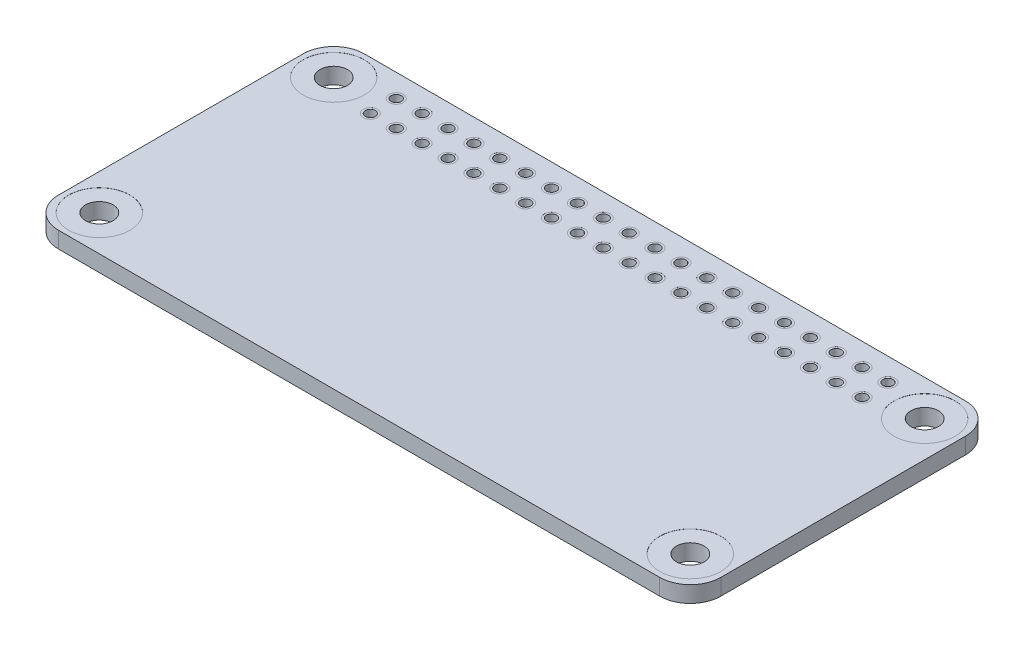
from build123d import *

# Parameters (mm, degrees)
BASES_W                          = 65
BASES_H                          = 30
BASE_DEPTH                       = 0.8
M2_5_CLEARANCE_HOLE_D            = 2.7
FASTENERAREAS_R                  = 3
FASTENERAREAS_R_2                = 1.35
FASTENERAREA_DEPTH               = 0.01
F_1_0_1_DIAMETER_HOLE_IO_D       = 1
SOLDERCONNECTIONCUTS_R           = 0.7
SOLDERCONNECTIONCUTS_R_2         = 0.5
SOLDERCONNECTIONCUT_DEPTH        = 0.001
LP_DIAHOLE_IO_COUNT              = 20
LP_DIAHOLE_IO_PITCH              = 2.54
LP_DIAHOLE_IO_COUNT_DIR2         = 2
LP_DIAHOLE_IO_PITCH_DIR2         = 2.54
LP_DIAHOLE_IO_COPY_1_SKETCH_R    = 0.7
LP_DIAHOLE_IO_COPY_1_SKETCH_R_2  = 0.5
LP_DIAHOLE_IO_COPY_1_DEPTH       = 0.001
LP_DIAHOLE_IO_COPY_2_SKETCH_R    = 0.7
LP_DIAHOLE_IO_COPY_2_SKETCH_R_2  = 0.5
LP_DIAHOLE_IO_COPY_2_DEPTH       = 0.001
LP_DIAHOLE_IO_COPY_3_SKETCH_R    = 0.7
LP_DIAHOLE_IO_COPY_3_SKETCH_R_2  = 0.5
LP_DIAHOLE_IO_COPY_3_DEPTH       = 0.001
LP_DIAHOLE_IO_COPY_4_SKETCH_R    = 0.7
LP_DIAHOLE_IO_COPY_4_SKETCH_R_2  = 0.5
LP_DIAHOLE_IO_COPY_4_DEPTH       = 0.001
LP_DIAHOLE_IO_COPY_5_SKETCH_R    = 0.7
LP_DIAHOLE_IO_COPY_5_SKETCH_R_2  = 0.5
LP_DIAHOLE_IO_COPY_5_DEPTH       = 0.001
LP_DIAHOLE_IO_COPY_6_SKETCH_R    = 0.7
LP_DIAHOLE_IO_COPY_6_SKETCH_R_2  = 0.5
LP_DIAHOLE_IO_COPY_6_DEPTH       = 0.001
LP_DIAHOLE_IO_COPY_7_SKETCH_R    = 0.7
LP_DIAHOLE_IO_COPY_7_SKETCH_R_2  = 0.5
LP_DIAHOLE_IO_COPY_7_DEPTH       = 0.001
LP_DIAHOLE_IO_COPY_8_SKETCH_R    = 0.7
LP_DIAHOLE_IO_COPY_8_SKETCH_R_2  = 0.5
LP_DIAHOLE_IO_COPY_8_DEPTH       = 0.001
LP_DIAHOLE_IO_COPY_9_SKETCH_R    = 0.7
LP_DIAHOLE_IO_COPY_9_SKETCH_R_2  = 0.5
LP_DIAHOLE_IO_COPY_9_DEPTH       = 0.001
LP_DIAHOLE_IO_COPY_10_SKETCH_R   = 0.7
LP_DIAHOLE_IO_COPY_10_SKETCH_R_2 = 0.5
LP_DIAHOLE_IO_COPY_10_DEPTH      = 0.001
LP_DIAHOLE_IO_COPY_11_SKETCH_R   = 0.7
LP_DIAHOLE_IO_COPY_11_SKETCH_R_2 = 0.5
LP_DIAHOLE_IO_COPY_11_DEPTH      = 0.001
LP_DIAHOLE_IO_COPY_12_SKETCH_R   = 0.7
LP_DIAHOLE_IO_COPY_12_SKETCH_R_2 = 0.5
LP_DIAHOLE_IO_COPY_12_DEPTH      = 0.001
LP_DIAHOLE_IO_COPY_13_SKETCH_R   = 0.7
LP_DIAHOLE_IO_COPY_13_SKETCH_R_2 = 0.5
LP_DIAHOLE_IO_COPY_13_DEPTH      = 0.001
LP_DIAHOLE_IO_COPY_14_SKETCH_R   = 0.7
LP_DIAHOLE_IO_COPY_14_SKETCH_R_2 = 0.5
LP_DIAHOLE_IO_COPY_14_DEPTH      = 0.001
LP_DIAHOLE_IO_COPY_15_SKETCH_R   = 0.7
LP_DIAHOLE_IO_COPY_15_SKETCH_R_2 = 0.5
LP_DIAHOLE_IO_COPY_15_DEPTH      = 0.001
LP_DIAHOLE_IO_COPY_16_SKETCH_R   = 0.7
LP_DIAHOLE_IO_COPY_16_SKETCH_R_2 = 0.5
LP_DIAHOLE_IO_COPY_16_DEPTH      = 0.001
LP_DIAHOLE_IO_COPY_17_SKETCH_R   = 0.7
LP_DIAHOLE_IO_COPY_17_SKETCH_R_2 = 0.5
LP_DIAHOLE_IO_COPY_17_DEPTH      = 0.001
LP_DIAHOLE_IO_COPY_18_SKETCH_R   = 0.7
LP_DIAHOLE_IO_COPY_18_SKETCH_R_2 = 0.5
LP_DIAHOLE_IO_COPY_18_DEPTH      = 0.001
LP_DIAHOLE_IO_COPY_19_SKETCH_R   = 0.7
LP_DIAHOLE_IO_COPY_19_SKETCH_R_2 = 0.5
LP_DIAHOLE_IO_COPY_19_DEPTH      = 0.001
LP_DIAHOLE_IO_COPY_20_SKETCH_R   = 0.7
LP_DIAHOLE_IO_COPY_20_SKETCH_R_2 = 0.5
LP_DIAHOLE_IO_COPY_20_DEPTH      = 0.001
LP_DIAHOLE_IO_COPY_21_SKETCH_R   = 0.7
LP_DIAHOLE_IO_COPY_21_SKETCH_R_2 = 0.5
LP_DIAHOLE_IO_COPY_21_DEPTH      = 0.001
LP_DIAHOLE_IO_COPY_22_SKETCH_R   = 0.7
LP_DIAHOLE_IO_COPY_22_SKETCH_R_2 = 0.5
LP_DIAHOLE_IO_COPY_22_DEPTH      = 0.001
LP_DIAHOLE_IO_COPY_23_SKETCH_R   = 0.7
LP_DIAHOLE_IO_COPY_23_SKETCH_R_2 = 0.5
LP_DIAHOLE_IO_COPY_23_DEPTH      = 0.001
LP_DIAHOLE_IO_COPY_24_SKETCH_R   = 0.7
LP_DIAHOLE_IO_COPY_24_SKETCH_R_2 = 0.5
LP_DIAHOLE_IO_COPY_24_DEPTH      = 0.001
LP_DIAHOLE_IO_COPY_25_SKETCH_R   = 0.7
LP_DIAHOLE_IO_COPY_25_SKETCH_R_2 = 0.5
LP_DIAHOLE_IO_COPY_25_DEPTH      = 0.001
LP_DIAHOLE_IO_COPY_26_SKETCH_R   = 0.7
LP_DIAHOLE_IO_COPY_26_SKETCH_R_2 = 0.5
LP_DIAHOLE_IO_COPY_26_DEPTH      = 0.001
LP_DIAHOLE_IO_COPY_27_SKETCH_R   = 0.7
LP_DIAHOLE_IO_COPY_27_SKETCH_R_2 = 0.5
LP_DIAHOLE_IO_COPY_27_DEPTH      = 0.001
LP_DIAHOLE_IO_COPY_28_SKETCH_R   = 0.7
LP_DIAHOLE_IO_COPY_28_SKETCH_R_2 = 0.5
LP_DIAHOLE_IO_COPY_28_DEPTH      = 0.001
LP_DIAHOLE_IO_COPY_29_SKETCH_R   = 0.7
LP_DIAHOLE_IO_COPY_29_SKETCH_R_2 = 0.5
LP_DIAHOLE_IO_COPY_29_DEPTH      = 0.001
LP_DIAHOLE_IO_COPY_30_SKETCH_R   = 0.7
LP_DIAHOLE_IO_COPY_30_SKETCH_R_2 = 0.5
LP_DIAHOLE_IO_COPY_30_DEPTH      = 0.001
LP_DIAHOLE_IO_COPY_31_SKETCH_R   = 0.7
LP_DIAHOLE_IO_COPY_31_SKETCH_R_2 = 0.5
LP_DIAHOLE_IO_COPY_31_DEPTH      = 0.001
LP_DIAHOLE_IO_COPY_32_SKETCH_R   = 0.7
LP_DIAHOLE_IO_COPY_32_SKETCH_R_2 = 0.5
LP_DIAHOLE_IO_COPY_32_DEPTH      = 0.001
LP_DIAHOLE_IO_COPY_33_SKETCH_R   = 0.7
LP_DIAHOLE_IO_COPY_33_SKETCH_R_2 = 0.5
LP_DIAHOLE_IO_COPY_33_DEPTH      = 0.001
LP_DIAHOLE_IO_COPY_34_SKETCH_R   = 0.7
LP_DIAHOLE_IO_COPY_34_SKETCH_R_2 = 0.5
LP_DIAHOLE_IO_COPY_34_DEPTH      = 0.001
LP_DIAHOLE_IO_COPY_35_SKETCH_R   = 0.7
LP_DIAHOLE_IO_COPY_35_SKETCH_R_2 = 0.5
LP_DIAHOLE_IO_COPY_35_DEPTH      = 0.001
LP_DIAHOLE_IO_COPY_36_SKETCH_R   = 0.7
LP_DIAHOLE_IO_COPY_36_SKETCH_R_2 = 0.5
LP_DIAHOLE_IO_COPY_36_DEPTH      = 0.001
LP_DIAHOLE_IO_COPY_37_SKETCH_R   = 0.7
LP_DIAHOLE_IO_COPY_37_SKETCH_R_2 = 0.5
LP_DIAHOLE_IO_COPY_37_DEPTH      = 0.001
LP_DIAHOLE_IO_COPY_38_SKETCH_R   = 0.7
LP_DIAHOLE_IO_COPY_38_SKETCH_R_2 = 0.5
LP_DIAHOLE_IO_COPY_38_DEPTH      = 0.001
LP_DIAHOLE_IO_COPY_39_SKETCH_R   = 0.7
LP_DIAHOLE_IO_COPY_39_SKETCH_R_2 = 0.5
LP_DIAHOLE_IO_COPY_39_DEPTH      = 0.001
CORNERRADIUS_R                   = 3
FCHM_COPY_1_SKETCH_R             = 3
FCHM_COPY_1_SKETCH_R_2           = 1.35
FCHM_COPY_1_DEPTH                = 0.01


with BuildPart() as part:
    # BaseS → Base (new, symmetric)
    with BuildSketch(Plane(origin=(0, 0, 0), x_dir=(1, 0, 0), z_dir=(0, 1, 0))):
        Rectangle(BASES_W, BASES_H)
    extrude(amount=BASE_DEPTH, both=True)

    # M2.5 Clearance Hole (through all)
    with Locations(Plane(origin=(0, 0.8, 0), x_dir=(1, 0, 0), z_dir=(0, 1, 0))):
        with Locations((-29, 11.5), (-29, -11.5)):
            m2_5_clearance_hole = Hole(M2_5_CLEARANCE_HOLE_D / 2)

    # FastenerAreaS → FastenerArea (cut)
    with BuildSketch(Plane(origin=(0, 0.8, 0), x_dir=(1, 0, 0), z_dir=(0, 1, 0))):
        with Locations(Location((-29, -11.5, 0), (0, 0, 270))):
            Circle(FASTENERAREAS_R)
        with Locations(Location((-29, -11.5, 0), (0, 0, 270))):
            Circle(FASTENERAREAS_R_2, mode=Mode.SUBTRACT)
        with Locations(Location((-29, 11.5, 0), (0, 0, 270))):
            Circle(FASTENERAREAS_R)
        with Locations(Location((-29, 11.5, 0), (0, 0, 270))):
            Circle(FASTENERAREAS_R_2, mode=Mode.SUBTRACT)
    fastenerarea = extrude(amount=-FASTENERAREA_DEPTH, mode=Mode.SUBTRACT)

    # VM FA: FastenerArea across plane
    add(fastenerarea.mirror(Plane.ZX), mode=Mode.SUBTRACT)

    # Ø1.0 (1) Diameter Hole IO (through all)
    with Locations(Plane(origin=(0, 0.8, 0), x_dir=(1, 0, 0), z_dir=(0, 1, 0))):
        with Locations((-24.13, 12.77)):
            f_1_0_1_diameter_hole_io = Hole(F_1_0_1_DIAMETER_HOLE_IO_D / 2)

    # SolderConnectionCutS → SolderConnectionCut (cut)
    with BuildSketch(Plane(origin=(0, 0.8, 0), x_dir=(1, 0, 0), z_dir=(0, 1, 0))):
        with Locations(Location((-24.13, 12.77, 0), (0, 0, 270))):
            Circle(SOLDERCONNECTIONCUTS_R)
        with Locations(Location((-24.13, 12.77, 0), (0, 0, 270))):
            Circle(SOLDERCONNECTIONCUTS_R_2, mode=Mode.SUBTRACT)
    solderconnectioncut = extrude(amount=-SOLDERCONNECTIONCUT_DEPTH, mode=Mode.SUBTRACT)

    # SCCVM: SolderConnectionCut across plane
    add(solderconnectioncut.mirror(Plane.ZX), mode=Mode.SUBTRACT)

    # LP DiaHole IO: Ø1.0 (1) Diameter Hole IO, SolderConnectionCut 20 × 2
    with Locations(*[(i * LP_DIAHOLE_IO_PITCH, 0, j * LP_DIAHOLE_IO_PITCH_DIR2) for i in range(LP_DIAHOLE_IO_COUNT) for j in range(LP_DIAHOLE_IO_COUNT_DIR2) if (i, j) != (0, 0)]):
        add(f_1_0_1_diameter_hole_io, mode=Mode.SUBTRACT)
        add(solderconnectioncut, mode=Mode.SUBTRACT)

    # LP DiaHole IO copy 1 sketch → LP DiaHole IO copy 1 (cut)
    with BuildSketch(Plane(origin=(0, -0.8, 2.54), x_dir=(1, 0, 0), z_dir=(0, -1, 0))):
        with Locations((-24.13, -12.77)):
            Circle(LP_DIAHOLE_IO_COPY_1_SKETCH_R)
        with Locations((-24.13, -12.77)):
            Circle(LP_DIAHOLE_IO_COPY_1_SKETCH_R_2, mode=Mode.SUBTRACT)
    extrude(amount=-LP_DIAHOLE_IO_COPY_1_DEPTH, mode=Mode.SUBTRACT)

    # LP DiaHole IO copy 2 sketch → LP DiaHole IO copy 2 (cut)
    with BuildSketch(Plane(origin=(2.54, -0.8, 0), x_dir=(1, 0, 0), z_dir=(0, -1, 0))):
        with Locations((-24.13, -12.77)):
            Circle(LP_DIAHOLE_IO_COPY_2_SKETCH_R)
        with Locations((-24.13, -12.77)):
            Circle(LP_DIAHOLE_IO_COPY_2_SKETCH_R_2, mode=Mode.SUBTRACT)
    extrude(amount=-LP_DIAHOLE_IO_COPY_2_DEPTH, mode=Mode.SUBTRACT)

    # LP DiaHole IO copy 3 sketch → LP DiaHole IO copy 3 (cut)
    with BuildSketch(Plane(origin=(2.54, -0.8, 2.54), x_dir=(1, 0, 0), z_dir=(0, -1, 0))):
        with Locations((-24.13, -12.77)):
            Circle(LP_DIAHOLE_IO_COPY_3_SKETCH_R)
        with Locations((-24.13, -12.77)):
            Circle(LP_DIAHOLE_IO_COPY_3_SKETCH_R_2, mode=Mode.SUBTRACT)
    extrude(amount=-LP_DIAHOLE_IO_COPY_3_DEPTH, mode=Mode.SUBTRACT)

    # LP DiaHole IO copy 4 sketch → LP DiaHole IO copy 4 (cut)
    with BuildSketch(Plane(origin=(5.08, -0.8, 0), x_dir=(1, 0, 0), z_dir=(0, -1, 0))):
        with Locations((-24.13, -12.77)):
            Circle(LP_DIAHOLE_IO_COPY_4_SKETCH_R)
        with Locations((-24.13, -12.77)):
            Circle(LP_DIAHOLE_IO_COPY_4_SKETCH_R_2, mode=Mode.SUBTRACT)
    extrude(amount=-LP_DIAHOLE_IO_COPY_4_DEPTH, mode=Mode.SUBTRACT)

    # LP DiaHole IO copy 5 sketch → LP DiaHole IO copy 5 (cut)
    with BuildSketch(Plane(origin=(5.08, -0.8, 2.54), x_dir=(1, 0, 0), z_dir=(0, -1, 0))):
        with Locations((-24.13, -12.77)):
            Circle(LP_DIAHOLE_IO_COPY_5_SKETCH_R)
        with Locations((-24.13, -12.77)):
            Circle(LP_DIAHOLE_IO_COPY_5_SKETCH_R_2, mode=Mode.SUBTRACT)
    extrude(amount=-LP_DIAHOLE_IO_COPY_5_DEPTH, mode=Mode.SUBTRACT)

    # LP DiaHole IO copy 6 sketch → LP DiaHole IO copy 6 (cut)
    with BuildSketch(Plane(origin=(7.62, -0.8, 0), x_dir=(1, 0, 0), z_dir=(0, -1, 0))):
        with Locations((-24.13, -12.77)):
            Circle(LP_DIAHOLE_IO_COPY_6_SKETCH_R)
        with Locations((-24.13, -12.77)):
            Circle(LP_DIAHOLE_IO_COPY_6_SKETCH_R_2, mode=Mode.SUBTRACT)
    extrude(amount=-LP_DIAHOLE_IO_COPY_6_DEPTH, mode=Mode.SUBTRACT)

    # LP DiaHole IO copy 7 sketch → LP DiaHole IO copy 7 (cut)
    with BuildSketch(Plane(origin=(7.62, -0.8, 2.54), x_dir=(1, 0, 0), z_dir=(0, -1, 0))):
        with Locations((-24.13, -12.77)):
            Circle(LP_DIAHOLE_IO_COPY_7_SKETCH_R)
        with Locations((-24.13, -12.77)):
            Circle(LP_DIAHOLE_IO_COPY_7_SKETCH_R_2, mode=Mode.SUBTRACT)
    extrude(amount=-LP_DIAHOLE_IO_COPY_7_DEPTH, mode=Mode.SUBTRACT)

    # LP DiaHole IO copy 8 sketch → LP DiaHole IO copy 8 (cut)
    with BuildSketch(Plane(origin=(10.16, -0.8, 0), x_dir=(1, 0, 0), z_dir=(0, -1, 0))):
        with Locations((-24.13, -12.77)):
            Circle(LP_DIAHOLE_IO_COPY_8_SKETCH_R)
        with Locations((-24.13, -12.77)):
            Circle(LP_DIAHOLE_IO_COPY_8_SKETCH_R_2, mode=Mode.SUBTRACT)
    extrude(amount=-LP_DIAHOLE_IO_COPY_8_DEPTH, mode=Mode.SUBTRACT)

    # LP DiaHole IO copy 9 sketch → LP DiaHole IO copy 9 (cut)
    with BuildSketch(Plane(origin=(10.16, -0.8, 2.54), x_dir=(1, 0, 0), z_dir=(0, -1, 0))):
        with Locations((-24.13, -12.77)):
            Circle(LP_DIAHOLE_IO_COPY_9_SKETCH_R)
        with Locations((-24.13, -12.77)):
            Circle(LP_DIAHOLE_IO_COPY_9_SKETCH_R_2, mode=Mode.SUBTRACT)
    extrude(amount=-LP_DIAHOLE_IO_COPY_9_DEPTH, mode=Mode.SUBTRACT)

    # LP DiaHole IO copy 10 sketch → LP DiaHole IO copy 10 (cut)
    with BuildSketch(Plane(origin=(12.7, -0.8, 0), x_dir=(1, 0, 0), z_dir=(0, -1, 0))):
        with Locations((-24.13, -12.77)):
            Circle(LP_DIAHOLE_IO_COPY_10_SKETCH_R)
        with Locations((-24.13, -12.77)):
            Circle(LP_DIAHOLE_IO_COPY_10_SKETCH_R_2, mode=Mode.SUBTRACT)
    extrude(amount=-LP_DIAHOLE_IO_COPY_10_DEPTH, mode=Mode.SUBTRACT)

    # LP DiaHole IO copy 11 sketch → LP DiaHole IO copy 11 (cut)
    with BuildSketch(Plane(origin=(12.7, -0.8, 2.54), x_dir=(1, 0, 0), z_dir=(0, -1, 0))):
        with Locations((-24.13, -12.77)):
            Circle(LP_DIAHOLE_IO_COPY_11_SKETCH_R)
        with Locations((-24.13, -12.77)):
            Circle(LP_DIAHOLE_IO_COPY_11_SKETCH_R_2, mode=Mode.SUBTRACT)
    extrude(amount=-LP_DIAHOLE_IO_COPY_11_DEPTH, mode=Mode.SUBTRACT)

    # LP DiaHole IO copy 12 sketch → LP DiaHole IO copy 12 (cut)
    with BuildSketch(Plane(origin=(15.24, -0.8, 0), x_dir=(1, 0, 0), z_dir=(0, -1, 0))):
        with Locations((-24.13, -12.77)):
            Circle(LP_DIAHOLE_IO_COPY_12_SKETCH_R)
        with Locations((-24.13, -12.77)):
            Circle(LP_DIAHOLE_IO_COPY_12_SKETCH_R_2, mode=Mode.SUBTRACT)
    extrude(amount=-LP_DIAHOLE_IO_COPY_12_DEPTH, mode=Mode.SUBTRACT)

    # LP DiaHole IO copy 13 sketch → LP DiaHole IO copy 13 (cut)
    with BuildSketch(Plane(origin=(15.24, -0.8, 2.54), x_dir=(1, 0, 0), z_dir=(0, -1, 0))):
        with Locations((-24.13, -12.77)):
            Circle(LP_DIAHOLE_IO_COPY_13_SKETCH_R)
        with Locations((-24.13, -12.77)):
            Circle(LP_DIAHOLE_IO_COPY_13_SKETCH_R_2, mode=Mode.SUBTRACT)
    extrude(amount=-LP_DIAHOLE_IO_COPY_13_DEPTH, mode=Mode.SUBTRACT)

    # LP DiaHole IO copy 14 sketch → LP DiaHole IO copy 14 (cut)
    with BuildSketch(Plane(origin=(17.78, -0.8, 0), x_dir=(1, 0, 0), z_dir=(0, -1, 0))):
        with Locations((-24.13, -12.77)):
            Circle(LP_DIAHOLE_IO_COPY_14_SKETCH_R)
        with Locations((-24.13, -12.77)):
            Circle(LP_DIAHOLE_IO_COPY_14_SKETCH_R_2, mode=Mode.SUBTRACT)
    extrude(amount=-LP_DIAHOLE_IO_COPY_14_DEPTH, mode=Mode.SUBTRACT)

    # LP DiaHole IO copy 15 sketch → LP DiaHole IO copy 15 (cut)
    with BuildSketch(Plane(origin=(17.78, -0.8, 2.54), x_dir=(1, 0, 0), z_dir=(0, -1, 0))):
        with Locations((-24.13, -12.77)):
            Circle(LP_DIAHOLE_IO_COPY_15_SKETCH_R)
        with Locations((-24.13, -12.77)):
            Circle(LP_DIAHOLE_IO_COPY_15_SKETCH_R_2, mode=Mode.SUBTRACT)
    extrude(amount=-LP_DIAHOLE_IO_COPY_15_DEPTH, mode=Mode.SUBTRACT)

    # LP DiaHole IO copy 16 sketch → LP DiaHole IO copy 16 (cut)
    with BuildSketch(Plane(origin=(20.32, -0.8, 0), x_dir=(1, 0, 0), z_dir=(0, -1, 0))):
        with Locations((-24.13, -12.77)):
            Circle(LP_DIAHOLE_IO_COPY_16_SKETCH_R)
        with Locations((-24.13, -12.77)):
            Circle(LP_DIAHOLE_IO_COPY_16_SKETCH_R_2, mode=Mode.SUBTRACT)
    extrude(amount=-LP_DIAHOLE_IO_COPY_16_DEPTH, mode=Mode.SUBTRACT)

    # LP DiaHole IO copy 17 sketch → LP DiaHole IO copy 17 (cut)
    with BuildSketch(Plane(origin=(20.32, -0.8, 2.54), x_dir=(1, 0, 0), z_dir=(0, -1, 0))):
        with Locations((-24.13, -12.77)):
            Circle(LP_DIAHOLE_IO_COPY_17_SKETCH_R)
        with Locations((-24.13, -12.77)):
            Circle(LP_DIAHOLE_IO_COPY_17_SKETCH_R_2, mode=Mode.SUBTRACT)
    extrude(amount=-LP_DIAHOLE_IO_COPY_17_DEPTH, mode=Mode.SUBTRACT)

    # LP DiaHole IO copy 18 sketch → LP DiaHole IO copy 18 (cut)
    with BuildSketch(Plane(origin=(22.86, -0.8, 0), x_dir=(1, 0, 0), z_dir=(0, -1, 0))):
        with Locations((-24.13, -12.77)):
            Circle(LP_DIAHOLE_IO_COPY_18_SKETCH_R)
        with Locations((-24.13, -12.77)):
            Circle(LP_DIAHOLE_IO_COPY_18_SKETCH_R_2, mode=Mode.SUBTRACT)
    extrude(amount=-LP_DIAHOLE_IO_COPY_18_DEPTH, mode=Mode.SUBTRACT)

    # LP DiaHole IO copy 19 sketch → LP DiaHole IO copy 19 (cut)
    with BuildSketch(Plane(origin=(22.86, -0.8, 2.54), x_dir=(1, 0, 0), z_dir=(0, -1, 0))):
        with Locations((-24.13, -12.77)):
            Circle(LP_DIAHOLE_IO_COPY_19_SKETCH_R)
        with Locations((-24.13, -12.77)):
            Circle(LP_DIAHOLE_IO_COPY_19_SKETCH_R_2, mode=Mode.SUBTRACT)
    extrude(amount=-LP_DIAHOLE_IO_COPY_19_DEPTH, mode=Mode.SUBTRACT)

    # LP DiaHole IO copy 20 sketch → LP DiaHole IO copy 20 (cut)
    with BuildSketch(Plane(origin=(25.4, -0.8, 0), x_dir=(1, 0, 0), z_dir=(0, -1, 0))):
        with Locations((-24.13, -12.77)):
            Circle(LP_DIAHOLE_IO_COPY_20_SKETCH_R)
        with Locations((-24.13, -12.77)):
            Circle(LP_DIAHOLE_IO_COPY_20_SKETCH_R_2, mode=Mode.SUBTRACT)
    extrude(amount=-LP_DIAHOLE_IO_COPY_20_DEPTH, mode=Mode.SUBTRACT)

    # LP DiaHole IO copy 21 sketch → LP DiaHole IO copy 21 (cut)
    with BuildSketch(Plane(origin=(25.4, -0.8, 2.54), x_dir=(1, 0, 0), z_dir=(0, -1, 0))):
        with Locations((-24.13, -12.77)):
            Circle(LP_DIAHOLE_IO_COPY_21_SKETCH_R)
        with Locations((-24.13, -12.77)):
            Circle(LP_DIAHOLE_IO_COPY_21_SKETCH_R_2, mode=Mode.SUBTRACT)
    extrude(amount=-LP_DIAHOLE_IO_COPY_21_DEPTH, mode=Mode.SUBTRACT)

    # LP DiaHole IO copy 22 sketch → LP DiaHole IO copy 22 (cut)
    with BuildSketch(Plane(origin=(27.94, -0.8, 0), x_dir=(1, 0, 0), z_dir=(0, -1, 0))):
        with Locations((-24.13, -12.77)):
            Circle(LP_DIAHOLE_IO_COPY_22_SKETCH_R)
        with Locations((-24.13, -12.77)):
            Circle(LP_DIAHOLE_IO_COPY_22_SKETCH_R_2, mode=Mode.SUBTRACT)
    extrude(amount=-LP_DIAHOLE_IO_COPY_22_DEPTH, mode=Mode.SUBTRACT)

    # LP DiaHole IO copy 23 sketch → LP DiaHole IO copy 23 (cut)
    with BuildSketch(Plane(origin=(27.94, -0.8, 2.54), x_dir=(1, 0, 0), z_dir=(0, -1, 0))):
        with Locations((-24.13, -12.77)):
            Circle(LP_DIAHOLE_IO_COPY_23_SKETCH_R)
        with Locations((-24.13, -12.77)):
            Circle(LP_DIAHOLE_IO_COPY_23_SKETCH_R_2, mode=Mode.SUBTRACT)
    extrude(amount=-LP_DIAHOLE_IO_COPY_23_DEPTH, mode=Mode.SUBTRACT)

    # LP DiaHole IO copy 24 sketch → LP DiaHole IO copy 24 (cut)
    with BuildSketch(Plane(origin=(30.48, -0.8, 0), x_dir=(1, 0, 0), z_dir=(0, -1, 0))):
        with Locations((-24.13, -12.77)):
            Circle(LP_DIAHOLE_IO_COPY_24_SKETCH_R)
        with Locations((-24.13, -12.77)):
            Circle(LP_DIAHOLE_IO_COPY_24_SKETCH_R_2, mode=Mode.SUBTRACT)
    extrude(amount=-LP_DIAHOLE_IO_COPY_24_DEPTH, mode=Mode.SUBTRACT)

    # LP DiaHole IO copy 25 sketch → LP DiaHole IO copy 25 (cut)
    with BuildSketch(Plane(origin=(30.48, -0.8, 2.54), x_dir=(1, 0, 0), z_dir=(0, -1, 0))):
        with Locations((-24.13, -12.77)):
            Circle(LP_DIAHOLE_IO_COPY_25_SKETCH_R)
        with Locations((-24.13, -12.77)):
            Circle(LP_DIAHOLE_IO_COPY_25_SKETCH_R_2, mode=Mode.SUBTRACT)
    extrude(amount=-LP_DIAHOLE_IO_COPY_25_DEPTH, mode=Mode.SUBTRACT)

    # LP DiaHole IO copy 26 sketch → LP DiaHole IO copy 26 (cut)
    with BuildSketch(Plane(origin=(33.02, -0.8, 0), x_dir=(1, 0, 0), z_dir=(0, -1, 0))):
        with Locations((-24.13, -12.77)):
            Circle(LP_DIAHOLE_IO_COPY_26_SKETCH_R)
        with Locations((-24.13, -12.77)):
            Circle(LP_DIAHOLE_IO_COPY_26_SKETCH_R_2, mode=Mode.SUBTRACT)
    extrude(amount=-LP_DIAHOLE_IO_COPY_26_DEPTH, mode=Mode.SUBTRACT)

    # LP DiaHole IO copy 27 sketch → LP DiaHole IO copy 27 (cut)
    with BuildSketch(Plane(origin=(33.02, -0.8, 2.54), x_dir=(1, 0, 0), z_dir=(0, -1, 0))):
        with Locations((-24.13, -12.77)):
            Circle(LP_DIAHOLE_IO_COPY_27_SKETCH_R)
        with Locations((-24.13, -12.77)):
            Circle(LP_DIAHOLE_IO_COPY_27_SKETCH_R_2, mode=Mode.SUBTRACT)
    extrude(amount=-LP_DIAHOLE_IO_COPY_27_DEPTH, mode=Mode.SUBTRACT)

    # LP DiaHole IO copy 28 sketch → LP DiaHole IO copy 28 (cut)
    with BuildSketch(Plane(origin=(35.56, -0.8, 0), x_dir=(1, 0, 0), z_dir=(0, -1, 0))):
        with Locations((-24.13, -12.77)):
            Circle(LP_DIAHOLE_IO_COPY_28_SKETCH_R)
        with Locations((-24.13, -12.77)):
            Circle(LP_DIAHOLE_IO_COPY_28_SKETCH_R_2, mode=Mode.SUBTRACT)
    extrude(amount=-LP_DIAHOLE_IO_COPY_28_DEPTH, mode=Mode.SUBTRACT)

    # LP DiaHole IO copy 29 sketch → LP DiaHole IO copy 29 (cut)
    with BuildSketch(Plane(origin=(35.56, -0.8, 2.54), x_dir=(1, 0, 0), z_dir=(0, -1, 0))):
        with Locations((-24.13, -12.77)):
            Circle(LP_DIAHOLE_IO_COPY_29_SKETCH_R)
        with Locations((-24.13, -12.77)):
            Circle(LP_DIAHOLE_IO_COPY_29_SKETCH_R_2, mode=Mode.SUBTRACT)
    extrude(amount=-LP_DIAHOLE_IO_COPY_29_DEPTH, mode=Mode.SUBTRACT)

    # LP DiaHole IO copy 30 sketch → LP DiaHole IO copy 30 (cut)
    with BuildSketch(Plane(origin=(38.1, -0.8, 0), x_dir=(1, 0, 0), z_dir=(0, -1, 0))):
        with Locations((-24.13, -12.77)):
            Circle(LP_DIAHOLE_IO_COPY_30_SKETCH_R)
        with Locations((-24.13, -12.77)):
            Circle(LP_DIAHOLE_IO_COPY_30_SKETCH_R_2, mode=Mode.SUBTRACT)
    extrude(amount=-LP_DIAHOLE_IO_COPY_30_DEPTH, mode=Mode.SUBTRACT)

    # LP DiaHole IO copy 31 sketch → LP DiaHole IO copy 31 (cut)
    with BuildSketch(Plane(origin=(38.1, -0.8, 2.54), x_dir=(1, 0, 0), z_dir=(0, -1, 0))):
        with Locations((-24.13, -12.77)):
            Circle(LP_DIAHOLE_IO_COPY_31_SKETCH_R)
        with Locations((-24.13, -12.77)):
            Circle(LP_DIAHOLE_IO_COPY_31_SKETCH_R_2, mode=Mode.SUBTRACT)
    extrude(amount=-LP_DIAHOLE_IO_COPY_31_DEPTH, mode=Mode.SUBTRACT)

    # LP DiaHole IO copy 32 sketch → LP DiaHole IO copy 32 (cut)
    with BuildSketch(Plane(origin=(40.64, -0.8, 0), x_dir=(1, 0, 0), z_dir=(0, -1, 0))):
        with Locations((-24.13, -12.77)):
            Circle(LP_DIAHOLE_IO_COPY_32_SKETCH_R)
        with Locations((-24.13, -12.77)):
            Circle(LP_DIAHOLE_IO_COPY_32_SKETCH_R_2, mode=Mode.SUBTRACT)
    extrude(amount=-LP_DIAHOLE_IO_COPY_32_DEPTH, mode=Mode.SUBTRACT)

    # LP DiaHole IO copy 33 sketch → LP DiaHole IO copy 33 (cut)
    with BuildSketch(Plane(origin=(40.64, -0.8, 2.54), x_dir=(1, 0, 0), z_dir=(0, -1, 0))):
        with Locations((-24.13, -12.77)):
            Circle(LP_DIAHOLE_IO_COPY_33_SKETCH_R)
        with Locations((-24.13, -12.77)):
            Circle(LP_DIAHOLE_IO_COPY_33_SKETCH_R_2, mode=Mode.SUBTRACT)
    extrude(amount=-LP_DIAHOLE_IO_COPY_33_DEPTH, mode=Mode.SUBTRACT)

    # LP DiaHole IO copy 34 sketch → LP DiaHole IO copy 34 (cut)
    with BuildSketch(Plane(origin=(43.18, -0.8, 0), x_dir=(1, 0, 0), z_dir=(0, -1, 0))):
        with Locations((-24.13, -12.77)):
            Circle(LP_DIAHOLE_IO_COPY_34_SKETCH_R)
        with Locations((-24.13, -12.77)):
            Circle(LP_DIAHOLE_IO_COPY_34_SKETCH_R_2, mode=Mode.SUBTRACT)
    extrude(amount=-LP_DIAHOLE_IO_COPY_34_DEPTH, mode=Mode.SUBTRACT)

    # LP DiaHole IO copy 35 sketch → LP DiaHole IO copy 35 (cut)
    with BuildSketch(Plane(origin=(43.18, -0.8, 2.54), x_dir=(1, 0, 0), z_dir=(0, -1, 0))):
        with Locations((-24.13, -12.77)):
            Circle(LP_DIAHOLE_IO_COPY_35_SKETCH_R)
        with Locations((-24.13, -12.77)):
            Circle(LP_DIAHOLE_IO_COPY_35_SKETCH_R_2, mode=Mode.SUBTRACT)
    extrude(amount=-LP_DIAHOLE_IO_COPY_35_DEPTH, mode=Mode.SUBTRACT)

    # LP DiaHole IO copy 36 sketch → LP DiaHole IO copy 36 (cut)
    with BuildSketch(Plane(origin=(45.72, -0.8, 0), x_dir=(1, 0, 0), z_dir=(0, -1, 0))):
        with Locations((-24.13, -12.77)):
            Circle(LP_DIAHOLE_IO_COPY_36_SKETCH_R)
        with Locations((-24.13, -12.77)):
            Circle(LP_DIAHOLE_IO_COPY_36_SKETCH_R_2, mode=Mode.SUBTRACT)
    extrude(amount=-LP_DIAHOLE_IO_COPY_36_DEPTH, mode=Mode.SUBTRACT)

    # LP DiaHole IO copy 37 sketch → LP DiaHole IO copy 37 (cut)
    with BuildSketch(Plane(origin=(45.72, -0.8, 2.54), x_dir=(1, 0, 0), z_dir=(0, -1, 0))):
        with Locations((-24.13, -12.77)):
            Circle(LP_DIAHOLE_IO_COPY_37_SKETCH_R)
        with Locations((-24.13, -12.77)):
            Circle(LP_DIAHOLE_IO_COPY_37_SKETCH_R_2, mode=Mode.SUBTRACT)
    extrude(amount=-LP_DIAHOLE_IO_COPY_37_DEPTH, mode=Mode.SUBTRACT)

    # LP DiaHole IO copy 38 sketch → LP DiaHole IO copy 38 (cut)
    with BuildSketch(Plane(origin=(48.26, -0.8, 0), x_dir=(1, 0, 0), z_dir=(0, -1, 0))):
        with Locations((-24.13, -12.77)):
            Circle(LP_DIAHOLE_IO_COPY_38_SKETCH_R)
        with Locations((-24.13, -12.77)):
            Circle(LP_DIAHOLE_IO_COPY_38_SKETCH_R_2, mode=Mode.SUBTRACT)
    extrude(amount=-LP_DIAHOLE_IO_COPY_38_DEPTH, mode=Mode.SUBTRACT)

    # LP DiaHole IO copy 39 sketch → LP DiaHole IO copy 39 (cut)
    with BuildSketch(Plane(origin=(48.26, -0.8, 2.54), x_dir=(1, 0, 0), z_dir=(0, -1, 0))):
        with Locations((-24.13, -12.77)):
            Circle(LP_DIAHOLE_IO_COPY_39_SKETCH_R)
        with Locations((-24.13, -12.77)):
            Circle(LP_DIAHOLE_IO_COPY_39_SKETCH_R_2, mode=Mode.SUBTRACT)
    extrude(amount=-LP_DIAHOLE_IO_COPY_39_DEPTH, mode=Mode.SUBTRACT)

    # CornerRadius
    cornerradius_edges = [part.edges().sort_by_distance(p)[0] for p in [
        (32.5, 0, 15),
        (-32.5, 0, 15),
        (-32.5, 0, -15),
        (32.5, 0, -15),
    ]]
    fillet(cornerradius_edges, radius=CORNERRADIUS_R)

    # FCHM: M2.5 Clearance Hole, FastenerArea across plane
    add(m2_5_clearance_hole.mirror(Plane(origin=(0, 0, 0), x_dir=(0, 0, 1), z_dir=(1, 0, 0))), mode=Mode.SUBTRACT)
    add(fastenerarea.mirror(Plane(origin=(0, 0, 0), x_dir=(0, 0, 1), z_dir=(1, 0, 0))), mode=Mode.SUBTRACT)

    # FCHM copy 1 sketch → FCHM copy 1 (cut)
    with BuildSketch(Plane(origin=(0, -0.8, 0), x_dir=(-1, 0, 0), z_dir=(0, -1, 0))):
        with Locations(Location((-29, -11.5, 0), (0, 0, 270))):
            Circle(FCHM_COPY_1_SKETCH_R)
        with Locations(Location((-29, -11.5, 0), (0, 0, 270))):
            Circle(FCHM_COPY_1_SKETCH_R_2, mode=Mode.SUBTRACT)
        with Locations(Location((-29, 11.5, 0), (0, 0, 270))):
            Circle(FCHM_COPY_1_SKETCH_R)
        with Locations(Location((-29, 11.5, 0), (0, 0, 270))):
            Circle(FCHM_COPY_1_SKETCH_R_2, mode=Mode.SUBTRACT)
    extrude(amount=-FCHM_COPY_1_DEPTH, mode=Mode.SUBTRACT)


solid = part.part
